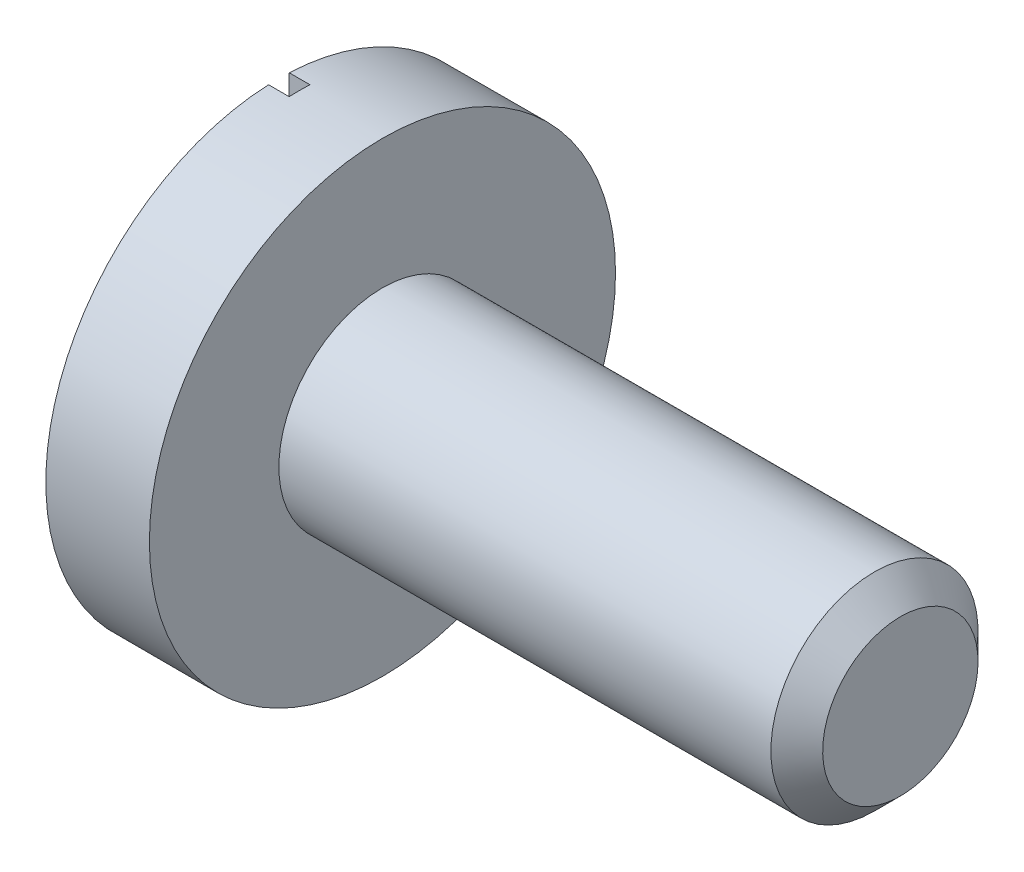
from build123d import *

# Parameters (mm, degrees)
CHAFL_N1_SIZE         = 0.125
CORTAR_EXTRUIR2_DEPTH = 0.1


with BuildPart() as part:
    # Croquis1 → Revolución1 (revolve)
    with BuildSketch(Plane.XY):
        Polygon((0, 0), (0, 1.125), (0.5, 1.125), (0.5, 0.5), (3, 0.5), (3, 0), align=None)
    revolve(axis=Axis((3, 0, 0), (-1, 0, 0)))

    # Chaflán1
    chafl_n1_edges = [part.edges().sort_by_distance(p)[0] for p in [
        (3, -0.5, 0),
    ]]
    chamfer(chafl_n1_edges, length=CHAFL_N1_SIZE)

    # Croquis6 → Cortar-Extruir2 (cut)
    with BuildSketch(Plane.ZY):
        with BuildLine():
            Line((-0.05, 1.12388834), (-0.05, -1.12388834))
            ThreePointArc((-0.05, -1.12388834), (0, -1.125), (0.05, -1.12388834))
            Line((0.05, -1.12388834), (0.05, 1.12388834))
            ThreePointArc((0.05, 1.12388834), (0, 1.125), (-0.05, 1.12388834))
        make_face()
    extrude(amount=-CORTAR_EXTRUIR2_DEPTH, mode=Mode.SUBTRACT)


solid = part.part
